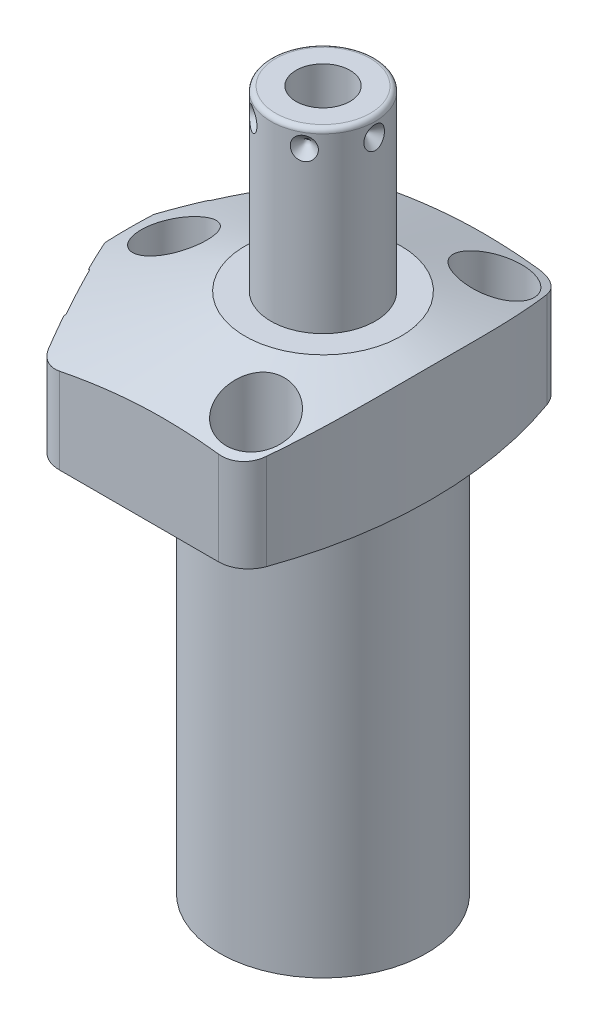
from build123d import *

# Parameters (mm, degrees)
CUT_EXTRUDE1_REACH = 28.975
CUT_EXTRUDE2_REACH = 28.975
S2D0002_OUTSIDE_W  = 122.011
S2D0002_OUTSIDE_H  = 101.742
CUT_EXTRUDE3_DEPTH = 38.0873
FILLET1_R          = 6.35
FILLET2_R          = 6.35
FILLET3_R          = 6.35
SKETCH17_R         = 10.4775
CUT_EXTRUDE4_DEPTH = 0.254
SKETCH18_R         = 5.5626
CUT_EXTRUDE5_DEPTH = 2.667
CIRPATTERN1_COUNT  = 6
HOLE1_D            = 8.7376
HOLE1_DEPTH        = 26.9748
HOLE1_CBORE_D      = 13.9954
HOLE1_CBORE_DEPTH  = 16.6624


with BuildPart() as part:
    # Sketch1 → Revolve1 (revolve)
    with BuildSketch(Plane(origin=(0, 0, 0), x_dir=(0, -1, 0), z_dir=(0, 0, 1)), mode=Mode.PRIVATE) as revolve1_sk:
        Polygon((0, 44.45), (-26.9748, 44.45), (-26.9748, 0), (84.1502, 0), (84.1502, 22.098), (0, 22.098), align=None)
    revolve(revolve1_sk.sketch.rotate(Axis((0, 32.53105, 0), (0, -1, 0)), 90), axis=Axis((0, 32.53105, 0), (0, -1, 0)))  # turned: the seam where the file's is

    # Sketch2 → Cut-Extrude1 (cut, up to next)
    with BuildSketch(Plane(origin=(0, 0, 0), x_dir=(0, 0, -1), z_dir=(0, -1, 0)), mode=Mode.PRIVATE) as cut_extrude1_sk1:
        with BuildLine():
            Line((34.1122, -28.498426468), (34.1122, 28.498426468))
            ThreePointArc((34.1122, 28.498426468), (44.45, 0), (34.1122, -28.498426468))
        make_face()
    cut_extrude1_tool1 = extrude(cut_extrude1_sk1.sketch, amount=-CUT_EXTRUDE1_REACH, mode=Mode.PRIVATE) & part.part
    add(cut_extrude1_tool1.solids().sort_by_distance((0, 0, -38.291522))[0], mode=Mode.SUBTRACT)
    # Sketch2 → Cut-Extrude1 (cut, up to next)
    with BuildSketch(Plane(origin=(0, 0, 0), x_dir=(0, 0, -1), z_dir=(0, -1, 0)), mode=Mode.PRIVATE) as cut_extrude1_sk2:
        with BuildLine():
            Line((-34.1122, 28.498426468), (-34.1122, -28.498426468))
            ThreePointArc((-34.1122, -28.498426468), (-44.45, 0), (-34.1122, 28.498426468))
        make_face()
    cut_extrude1_tool2 = extrude(cut_extrude1_sk2.sketch, amount=-CUT_EXTRUDE1_REACH, mode=Mode.PRIVATE) & part.part
    add(cut_extrude1_tool2.solids().sort_by_distance((0, 0, 38.291522))[0], mode=Mode.SUBTRACT)

    # Sketch3 → Cut-Extrude2 (cut, up to next)
    with BuildSketch(Plane(origin=(0, 0, 0), x_dir=(-1, 0, 0), z_dir=(0, -1, 0)), mode=Mode.PRIVATE) as cut_extrude2_sk1:
        with BuildLine():
            Line((25.904926114, 34.1122), (44.042704589, 0))
            Line((44.042704589, 0), (25.904926114, -34.1122))
            Line((25.904926114, -34.1122), (28.498426468, -34.1122))
            ThreePointArc((28.498426468, -34.1122), (44.45, 0), (28.498426468, 34.1122))
            Line((28.498426468, 34.1122), (25.904926114, 34.1122))
        make_face()
    cut_extrude2_tool1 = extrude(cut_extrude2_sk1.sketch, amount=-CUT_EXTRUDE2_REACH, mode=Mode.PRIVATE) & part.part
    add(cut_extrude2_tool1.solids().sort_by_distance((-27.201676, 0, -33.4052))[0], mode=Mode.SUBTRACT)

    # S2D0002 outside → Cut-Extrude3 (cut)
    with BuildSketch(Plane(origin=(0, 0, 0), x_dir=(-1, 0, 0), z_dir=(0, -1, 0))):
        with Locations((-0.2035, 0)):
            Rectangle(S2D0002_OUTSIDE_W, S2D0002_OUTSIDE_H)
        with BuildLine():
            Line((41.275, 85.424995881), (41.275, -85.424995881))
            ThreePointArc((41.275, -85.424995881), (-23.0124, 0), (41.275, 85.424995881))
        make_face(mode=Mode.SUBTRACT)
    extrude(amount=-CUT_EXTRUDE3_DEPTH, mode=Mode.SUBTRACT)

    # Fillet1
    fillet1_edges = [part.edges().sort_by_distance(p)[0] for p in [
        (16.207270797, 13.4874, 34.1122),
        (16.207270797, 13.4874, -34.1122),
    ]]
    fillet(fillet1_edges, radius=FILLET1_R)

    # Fillet2
    fillet2_edges = [part.edges().sort_by_distance(p)[0] for p in [
        (-25.904926114, 13.4874, 34.1122),
    ]]
    fillet(fillet2_edges, radius=FILLET2_R)

    # Fillet3
    fillet3_edges = [part.edges().sort_by_distance(p)[0] for p in [
        (-25.904926114, 13.4874, -34.1122),
    ]]
    fillet(fillet3_edges, radius=FILLET3_R)

    # Sketch5 → Cut-Revolve1 (revolve, cut)
    with BuildSketch(Plane.XY, mode=Mode.PRIVATE) as cut_revolve1_sk:
        Polygon((-16.637, 26.9748), (-47.625, 15.696090381), (-47.625, 26.9748), align=None)
    revolve(cut_revolve1_sk.sketch.rotate(Axis((0, 7.66490951, 0), (0, 1, 0)), 90), axis=Axis((0, 7.66490951, 0), (0, 1, 0)), mode=Mode.SUBTRACT)  # turned: the seam where the file's is

    # Sketch6 → Cut-Revolve2 (revolve, cut)
    with BuildSketch(Plane(origin=(-34.111267534, 10.287, -18.137282674), x_dir=(0.469471563, 0, -0.882947593), z_dir=(0, 1, 0))):
        Polygon((0, 0), (6.1849, 0), (5.642306865, -2.5527), (4.9784, -3.216606865), (4.9784, -15.748), (0, -15.748), align=None)
    revolve(axis=Axis((-19.511375907, 10.287, -10.374382594), (-0.882947593, 0, -0.469471563)), mode=Mode.SUBTRACT)

    # Sketch7 → Cut-Revolve3 (revolve, cut)
    with BuildSketch(Plane(origin=(-34.111267534, 10.287, 18.137282674), x_dir=(-0.469471563, 0, -0.882947593), z_dir=(0, 1, 0))):
        Polygon((0, 0), (6.1849, 0), (5.642306865, -2.5527), (4.9784, -3.216606865), (4.9784, -15.748), (0, -15.748), align=None)
    revolve(axis=Axis((-19.511375907, 10.287, 10.374382594), (-0.882947593, 0, 0.469471563)), mode=Mode.SUBTRACT)

    # Sketch8 → Cut-Revolve4 (revolve, cut)
    with BuildSketch(Plane(origin=(-13.4874, 2.667, -26.5938), x_dir=(-1, 0, 0), z_dir=(0, 0, 1)), mode=Mode.PRIVATE) as cut_revolve4_sk:
        Polygon((0, 0), (4.5466, 0), (4.106586662, -2.0701), (3.4544, -2.722286662), (3.4544, -12.573), (0, -12.573), align=None)
    revolve(cut_revolve4_sk.sketch.rotate(Axis((-13.4874, 15.86865, -26.5938), (0, -1, 0)), 270), axis=Axis((-13.4874, 15.86865, -26.5938), (0, -1, 0)), mode=Mode.SUBTRACT)  # turned: the seam where the file's is

    # Sketch9 → Cut-Revolve5 (revolve, cut)
    with BuildSketch(Plane(origin=(-13.4874, 2.667, 26.5938), x_dir=(-1, 0, 0), z_dir=(0, 0, 1)), mode=Mode.PRIVATE) as cut_revolve5_sk:
        Polygon((0, 0), (4.5466, 0), (4.106586662, -2.0701), (3.4544, -2.722286662), (3.4544, -12.573), (0, -12.573), align=None)
    revolve(cut_revolve5_sk.sketch.rotate(Axis((-13.4874, 15.86865, 26.5938), (0, -1, 0)), 270), axis=Axis((-13.4874, 15.86865, 26.5938), (0, -1, 0)), mode=Mode.SUBTRACT)  # turned: the seam where the file's is

    # Sketch17 → Cut-Extrude4 (cut)
    with BuildSketch(Plane(origin=(-34.335536223, 0, 18.256528451), x_dir=(0.469471563, 0, 0.882947593), z_dir=(-0.882947593, 0, 0.469471563))):
        with Locations((0, 10.287)):
            Circle(SKETCH17_R)
    cut_extrude4 = extrude(amount=-CUT_EXTRUDE4_DEPTH, mode=Mode.SUBTRACT)

    # Sketch18 → Cut-Extrude5 (cut)
    with BuildSketch(Plane.XZ):
        with Locations(Location((-13.4874, 26.5938, 0), (0, 0, 270))):  # turned: the seam where the file's is
            Circle(SKETCH18_R)
    cut_extrude5 = extrude(amount=-CUT_EXTRUDE5_DEPTH, mode=Mode.SUBTRACT)

    # Mirror1: Cut-Extrude4, Cut-Extrude5 across plane
    add(cut_extrude4.mirror(Plane.XY), mode=Mode.SUBTRACT)
    add(cut_extrude5.mirror(Plane.XY), mode=Mode.SUBTRACT)

    # Sketch10 → Revolve2 (revolve)
    with BuildSketch(Plane(origin=(0, 0, 0), x_dir=(0, 0, -1), z_dir=(1, 0, 0)), mode=Mode.PRIVATE) as revolve2_sk:
        with BuildLine():
            Line((0, 26.9748), (-11.1125, 26.9748))
            Line((-11.1125, 26.9748), (-11.1125, 63.8302))
            ThreePointArc((-11.1125, 63.8302), (-10.81492049, 64.54862049), (-10.0965, 64.8462))
            Line((-10.0965, 64.8462), (0, 64.8462))
            Line((0, 64.8462), (0, 26.9748))
        make_face()
    revolve(revolve2_sk.sketch.rotate(Axis((0, 14.351681477, 0), (0, 1, 0)), 180), axis=Axis((0, 14.351681477, 0), (0, 1, 0)))  # turned: the seam where the file's is

    # S2D0001 → Cut-Revolve6 (revolve, cut)
    with BuildSketch(Plane(origin=(5.7531, 64.8462, 0), x_dir=(1, 0, 0), z_dir=(0, 0, 1)), mode=Mode.PRIVATE) as cut_revolve6_sk:
        Polygon((0, 0), (0, -17.018), (-5.7531, -20.474811227), (-5.7531, 0), align=None)
    revolve(cut_revolve6_sk.sketch.rotate(Axis((0, 37.109882775, 0), (0, 1, 0)), 90), axis=Axis((0, 37.109882775, 0), (0, 1, 0)), mode=Mode.SUBTRACT)  # turned: the seam where the file's is

    # Sketch14 → Revolve3 (revolve)
    with BuildSketch(Plane(origin=(-13.4874, 0, 26.5938), x_dir=(0, 0, -1), z_dir=(1, 0, 0))):
        with BuildLine():
            Line((5.461, 2.667), (5.461, 0.9398))
            Line((5.461, 0.9398), (5.301559456, 0.9398))
            ThreePointArc((5.301559456, 0.9398), (4.572, -0.4572), (3.842440544, 0.9398))
            Line((3.842440544, 0.9398), (3.175, 0.9398))
            ThreePointArc((3.175, 0.9398), (2.815789755, 0.791010245), (2.667, 0.4318))
            Line((2.667, 0.4318), (2.667, 0.127))
            Line((2.667, 0.127), (1.5875, 0.127))
            Line((1.5875, 0.127), (1.5875, 10.6172))
            Line((1.5875, 10.6172), (3.2512, 10.6172))
            Line((3.2512, 10.6172), (3.2512, 2.667))
            Line((3.2512, 2.667), (5.461, 2.667))
        make_face()
    revolve3 = revolve(axis=Axis((-13.4874, -1.01092, 26.5938), (0, 1, 0)))

    # Sketch15 → Cut-Revolve7 (revolve, cut)
    with BuildSketch(Plane(origin=(-11.1125, 60.8838, 0), x_dir=(0, 1, 0), z_dir=(0, 0, 1)), mode=Mode.PRIVATE) as cut_revolve7_sk:
        Polygon((0, 0), (2.413, 0), (0, -2.413), align=None)
    cut_revolve7 = revolve(cut_revolve7_sk.sketch.rotate(Axis((-6.003069898, 60.8838, 0), (-1, 0, 0)), 270), axis=Axis((-6.003069898, 60.8838, 0), (-1, 0, 0)), mode=Mode.SUBTRACT)  # turned: the seam where the file's is

    # CirPattern1: Cut-Revolve7 ×6 about axis
    cirpattern1_axis = Axis((0, 14.351681477, 0), (0, -1, 0))
    for i in range(1, CIRPATTERN1_COUNT):
        add(cut_revolve7.rotate(cirpattern1_axis, i * 360 / CIRPATTERN1_COUNT), mode=Mode.SUBTRACT)

    # Hole1
    with Locations(Plane(origin=(0, 26.9748, 0), x_dir=(-1, 0, 0), z_dir=(0, 1, 0))):
        with Locations((-11.1252, -25.4), (31.75, 0), (-11.1252, 25.4)):
            CounterBoreHole(HOLE1_D / 2, HOLE1_CBORE_D / 2, HOLE1_CBORE_DEPTH, depth=HOLE1_DEPTH)

    # Mirror2: Revolve3 across plane
    add(revolve3.mirror(Plane.XY))


solid = part.part
